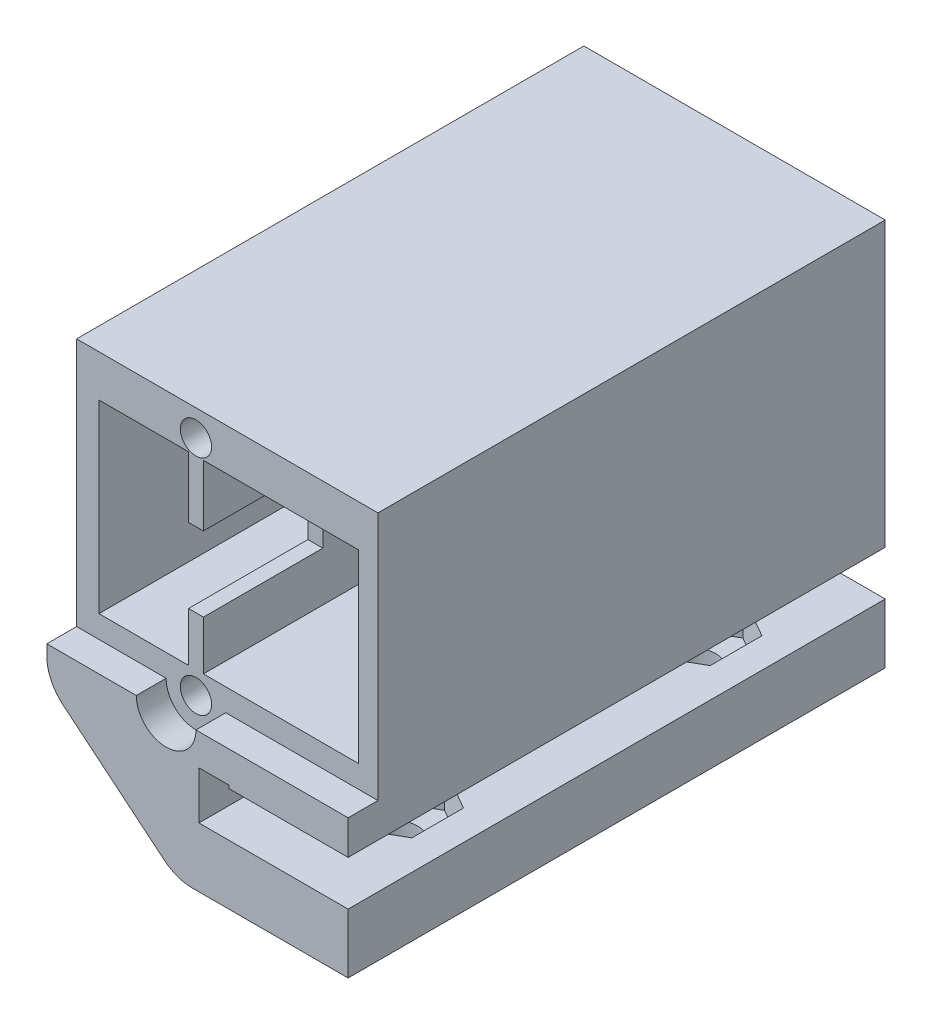
from build123d import *

# Parameters (mm, degrees)
ESBO_O1_W                = 6
ESBO_O1_H                = 12.4
ESBO_O1_W_2              = 10.4
ESBO_O1_R                = 1
ESBO_O1_R_2              = 2.5
RESSALTO_EXTRUS_O1_DEPTH = 18
CORTE_EXTRUS_O5_START    = 18
ESBO_O1_3_W              = 6
ESBO_O1_3_H              = 12.4
ESBO_O1_3_W_2            = 10.4
ESBO_O1_3_R              = 1
ESBO_O1_3_R_2            = 2.5
CORTE_EXTRUS_O5_DEPTH    = 34
ESBO_O3_R                = 1.05
ESBO_O3_W                = 1
ESBO_O3_H                = 5
CORTE_EXTRUS_O3_DEPTH    = 10
CORTE_EXTRUS_O4_DEPTH    = 2
ESBO_O5_R                = 1.65
CORTE_EXTRUS_O6_DEPTH    = 2.5
ESBO_O5_2_R              = 1.65
CORTE_EXTRUS_O7_DEPTH    = 5
FILETE1_R                = 3


with BuildPart() as part:
    # Esboço1 → Ressalto-extrusão1 (new body, symmetric)
    with BuildSketch(Plane.XY):
        Polygon((-1.4, -16.6), (-10.1, -9.4), (-10.1, 9.4), (10.1, 9.4), (10.1, -9.6), (2.1, -9.6), (2.1, -9.4), (0.1, -9.4), (0.1, -12.6), (10.1, -12.6), (10.1, -16.6), align=None)
        with Locations((-5.6, 0.4)):
            Rectangle(ESBO_O1_W, ESBO_O1_H, mode=Mode.SUBTRACT)
        with Locations((3.6, 0.4)):
            Rectangle(ESBO_O1_W_2, ESBO_O1_H, mode=Mode.SUBTRACT)
        with Locations((-5.6, 0.4)):
            Rectangle(ESBO_O1_W, ESBO_O1_H)
        with Locations((3.6, 0.4)):
            Rectangle(ESBO_O1_W_2, ESBO_O1_H)
        with Locations((3.6, 4.9)):
            Circle(ESBO_O1_R, mode=Mode.SUBTRACT)
        with Locations((3.6, -4.1)):
            Circle(ESBO_O1_R, mode=Mode.SUBTRACT)
        with Locations((3.6, 0.4)):
            Circle(ESBO_O1_R_2, mode=Mode.SUBTRACT)
    extrude(amount=RESSALTO_EXTRUS_O1_DEPTH, both=True)

    # Esboço1<3> → Corte-extrusão5 (cut)
    with BuildSketch(Plane.XY.offset(CORTE_EXTRUS_O5_START)):
        with Locations((-5.6, 0.4)):
            Rectangle(ESBO_O1_3_W, ESBO_O1_3_H)
        with Locations((3.6, 0.4)):
            Rectangle(ESBO_O1_3_W_2, ESBO_O1_3_H)
        with Locations((3.6, 4.9)):
            Circle(ESBO_O1_3_R, mode=Mode.SUBTRACT)
        with Locations((3.6, -4.1)):
            Circle(ESBO_O1_3_R, mode=Mode.SUBTRACT)
        with Locations((3.6, 0.4)):
            Circle(ESBO_O1_3_R_2, mode=Mode.SUBTRACT)
    extrude(amount=-CORTE_EXTRUS_O5_DEPTH, mode=Mode.SUBTRACT)

    # Esboço3 → Corte-extrusão3 (cut)
    with BuildSketch(Plane.XY.offset(18)):
        with Locations((-2.1, 7.65)):
            Circle(ESBO_O3_R)
        with Locations((-2.1, -7.3)):
            Circle(ESBO_O3_R)
        with Locations((-2.1, 0)):
            Rectangle(ESBO_O3_W, ESBO_O3_H)
    extrude(amount=-CORTE_EXTRUS_O3_DEPTH, mode=Mode.SUBTRACT)

    # Esboço4 → Corte-extrusão4 (cut)
    with BuildSketch(Plane.XY.offset(18)):
        with BuildLine():
            Line((-10.1, 9.4), (-10.1, -7.3))
            Line((-10.1, -7.3), (-4.1, -7.3))
            ThreePointArc((-4.1, -7.3), (-2.1, -9.3), (-0.1, -7.3))
            Line((-0.1, -7.3), (10.1, -7.3))
            Line((10.1, -7.3), (10.1, 9.4))
            Line((10.1, 9.4), (-10.1, 9.4))
        make_face()
    extrude(amount=-CORTE_EXTRUS_O4_DEPTH, mode=Mode.SUBTRACT)

    # Esboço5 → Corte-extrusão6 (cut)
    with BuildSketch(Plane(origin=(0, -12.6, 0), x_dir=(1, 0, 0), z_dir=(0, 1, 0))):
        Polygon((5.1, 6.535898385), (8.1, 8.267949192), (8.1, 11.732050808), (5.1, 13.464101615), (2.1, 11.732050808), (2.1, 8.267949192), align=None)
        with Locations((5.1, 10)):
            Circle(ESBO_O5_R, mode=Mode.SUBTRACT)
        Polygon((5.1, -13.464101615), (8.1, -11.732050808), (8.1, -8.267949192), (5.1, -6.535898385), (2.1, -8.267949192), (2.1, -11.732050808), align=None)
        with Locations((5.1, -10)):
            Circle(ESBO_O5_R, mode=Mode.SUBTRACT)
    extrude(amount=-CORTE_EXTRUS_O6_DEPTH, mode=Mode.SUBTRACT)

    # Esboço5<2> → Corte-extrusão7 (cut, through all)
    with BuildSketch(Plane(origin=(0, -12.6, 0), x_dir=(1, 0, 0), z_dir=(0, 1, 0))):
        with Locations((5.1, -10)):
            Circle(ESBO_O5_2_R)
        with Locations((5.1, 10)):
            Circle(ESBO_O5_2_R)
    extrude(amount=-CORTE_EXTRUS_O7_DEPTH, mode=Mode.SUBTRACT)

    # Filete1
    filete1_edges = [part.edges().sort_by_distance(p)[0] for p in [
        (-10.1, -9.4, 0),
        (-1.4, -16.6, 0),
    ]]
    fillet(filete1_edges, radius=FILETE1_R)


solid = part.part
